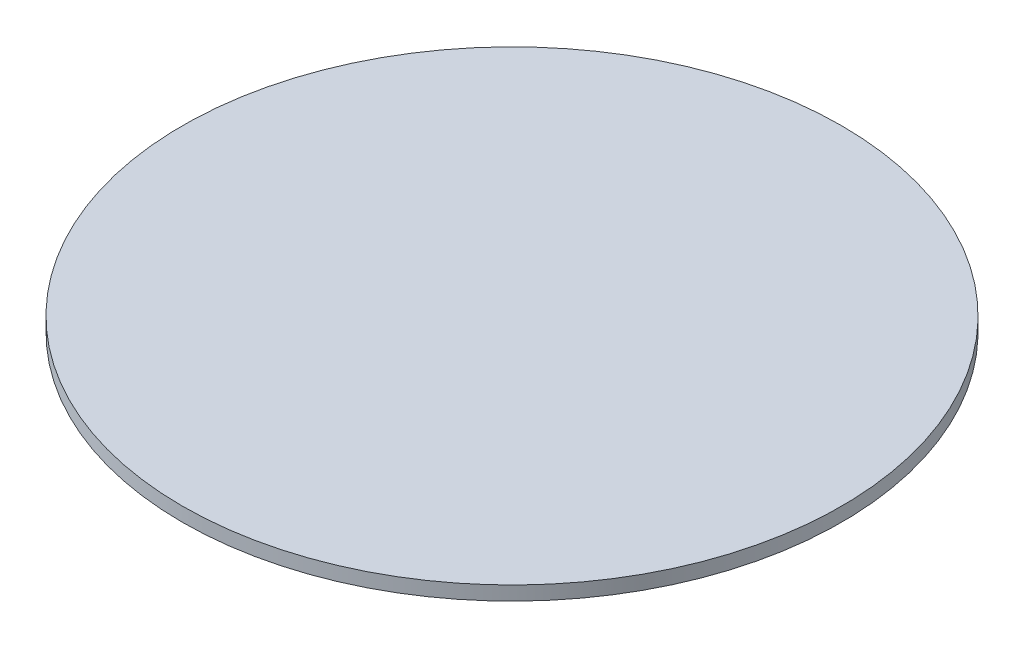
from build123d import *

# Parameters (mm, degrees)
SKETCH1_R           = 40
BOSS_EXTRUDE1_DEPTH = 1.7
SCALE1_SCALE        = 0.75


with BuildPart() as part:
    # Sketch1 → Boss-Extrude1 (new body)
    with BuildSketch(Plane(origin=(0, 0, 0), x_dir=(1, 0, 0), z_dir=(0, 1, 0))):
        Circle(SKETCH1_R)
    extrude(amount=BOSS_EXTRUDE1_DEPTH)


with BuildPart() as part_1:
    # Scale1: scaled about (0, 0.85, 0)
    add(part.part.scale(SCALE1_SCALE).moved(Location((0, 0.2125, 0))))


solid = part_1.part
